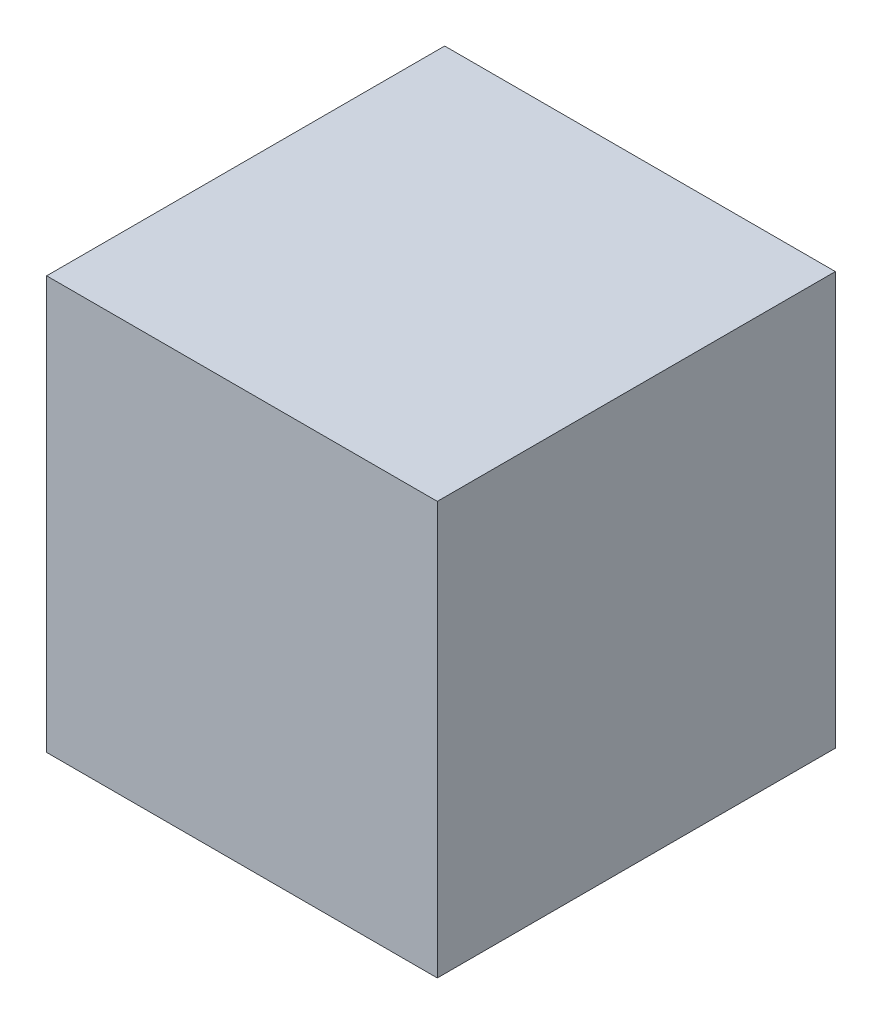
from build123d import *

# Parameters (mm, degrees)
SKETCH1_W           = 168.275
SKETCH1_H           = 177.8
BOSS_EXTRUDE1_DEPTH = 171.45


with BuildPart() as part:
    # Sketch1 → Boss-Extrude1 (new body)
    with BuildSketch(Plane.XY):
        with Locations((84.1375, 88.9)):
            Rectangle(SKETCH1_W, SKETCH1_H)
    extrude(amount=BOSS_EXTRUDE1_DEPTH)


solid = part.part
